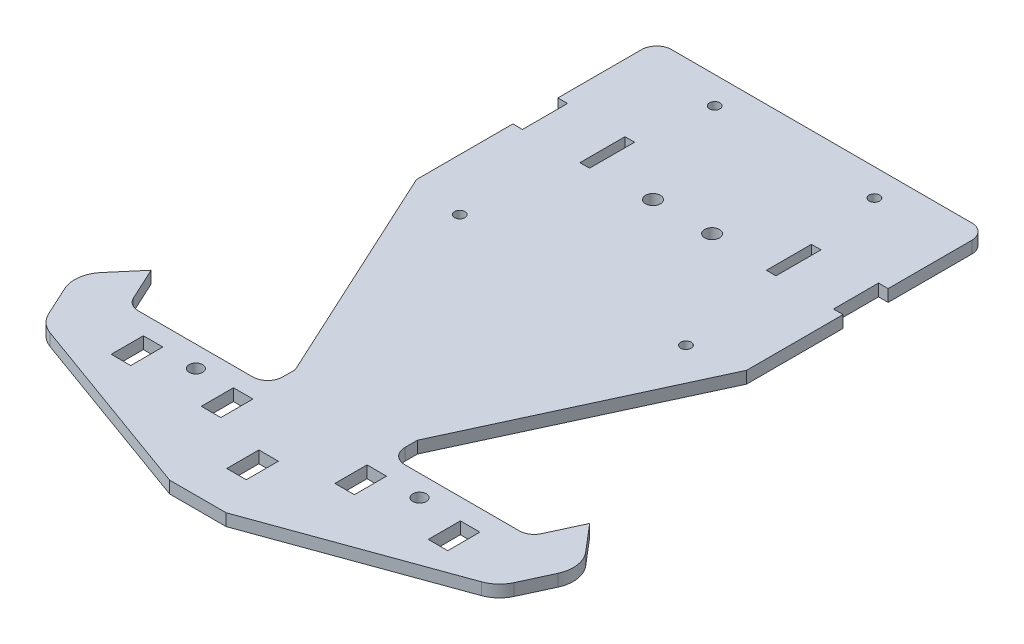
from build123d import *

# Parameters (mm, degrees)
SKETCH1_R           = 2.25
SKETCH1_W           = 6.5
SKETCH1_H           = 10.7
BOSS_EXTRUDE1_DEPTH = 2
SKETCH3_W           = 4
SKETCH3_H           = 15
BOSS_EXTRUDE2_DEPTH = 16
FILLET1_R           = 10
FILLET2_R           = 4
CHAMFER1_SIZE       = 3
CHAMFER1_SIZE2      = 5.196152423
CUT_EXTRUDE2_DEPTH  = 16
SKETCH10_R          = 2.468429883
SKETCH10_R_2        = 1.75
SKETCH10_W          = 3.2
SKETCH10_H          = 15
CUT_EXTRUDE3_DEPTH  = 4
SKETCH12_W          = 53.277727804
SKETCH12_H          = 68.29561081
CUT_EXTRUDE4_DEPTH  = 23


with BuildPart() as part:
    # Sketch1 → Boss-Extrude1 (new body, symmetric)
    with BuildSketch(Plane(origin=(0, -35, 0), x_dir=(1, 0, 0), z_dir=(0, 1, 0))):
        with BuildLine():
            Line((-50, 76.225749335), (50, 76.225749335))
            ThreePointArc((50, 76.225749335), (53.535533906, 74.761283241), (55, 71.225749335))
            Line((55, 71.225749335), (55, -3.774250665))
            Line((55, -3.774250665), (20.347942177, -78.774250665))
            Line((20.347942177, -78.774250665), (20.347942177, -82.95646352))
            ThreePointArc((20.347942177, -82.95646352), (21.812408271, -86.491997426), (25.347942177, -87.95646352))
            Line((25.347942177, -87.95646352), (63.43950887, -87.95646352))
            ThreePointArc((63.43950887, -87.95646352), (66.133427762, -87.168683956), (67.978460954, -85.053583921))
            Line((67.978460954, -85.053583921), (73.038309614, -74.102180936))
            Line((73.038309614, -74.102180936), (80.685361178, -83.086313097))
            ThreePointArc((80.685361178, -83.086313097), (82.977793564, -88.210367772), (82.148282135, -93.762222718))
            Line((82.148282135, -93.762222718), (77.534981649, -103.747128614))
            ThreePointArc((77.534981649, -103.747128614), (75.219554646, -106.919630821), (71.860949779, -108.955741281))
            Line((71.860949779, -108.955741281), (9.40285347, -131.565833476))
            Line((9.40285347, -131.565833476), (-9.40285347, -131.565833476))
            Line((-9.40285347, -131.565833476), (-71.860949779, -108.955741281))
            ThreePointArc((-71.860949779, -108.955741281), (-75.219554646, -106.919630821), (-77.534981649, -103.747128614))
            Line((-77.534981649, -103.747128614), (-82.148282135, -93.762222718))
            ThreePointArc((-82.148282135, -93.762222718), (-82.977793564, -88.210367772), (-80.685361178, -83.086313097))
            Line((-80.685361178, -83.086313097), (-73.038309614, -74.102180936))
            Line((-73.038309614, -74.102180936), (-67.978460954, -85.053583921))
            ThreePointArc((-67.978460954, -85.053583921), (-66.133427762, -87.168683956), (-63.43950887, -87.95646352))
            Line((-63.43950887, -87.95646352), (-25.347942177, -87.95646352))
            ThreePointArc((-25.347942177, -87.95646352), (-21.812408271, -86.491997426), (-20.347942177, -82.95646352))
            Line((-20.347942177, -82.95646352), (-20.347942177, -78.774250665))
            Line((-20.347942177, -78.774250665), (-55, -3.774250665))
            Line((-55, -3.774250665), (-55, 71.225749335))
            ThreePointArc((-55, 71.225749335), (-53.535533906, 74.761283241), (-50, 76.225749335))
        make_face()
        with Locations((-37.233481524, -94.993785432)):
            Circle(SKETCH1_R, mode=Mode.SUBTRACT)
        with Locations((37.266518397, -94.993786505)):
            Circle(SKETCH1_R, mode=Mode.SUBTRACT)
        with Locations((-52.183481524, -99.643785432)):
            Rectangle(SKETCH1_W, SKETCH1_H, mode=Mode.SUBTRACT)
        with Locations((-22.183481524, -99.643785432)):
            Rectangle(SKETCH1_W, SKETCH1_H, mode=Mode.SUBTRACT)
        with Locations((22.316518476, -99.643785432)):
            Rectangle(SKETCH1_W, SKETCH1_H, mode=Mode.SUBTRACT)
        with Locations((54.016518476, -100.243785432)):
            Rectangle(SKETCH1_W, SKETCH1_H, mode=Mode.SUBTRACT)
        with Locations((0, -113.343785432)):
            Rectangle(SKETCH1_W, SKETCH1_H, mode=Mode.SUBTRACT)
    extrude(amount=BOSS_EXTRUDE1_DEPTH, both=True)

    # Sketch3 → Boss-Extrude2 (add)
    with BuildSketch(Plane.XZ.offset(37)):
        with Locations((0, 80.45646352)):
            Rectangle(SKETCH3_W, SKETCH3_H)
    extrude(amount=BOSS_EXTRUDE2_DEPTH)

    # Fillet1
    fillet1_edges = [part.edges().sort_by_distance(p)[0] for p in [
        (0, -53, 87.95646352),
    ]]
    fillet(fillet1_edges, radius=FILLET1_R)

    # Fillet2
    fillet2_edges = [part.edges().sort_by_distance(p)[0] for p in [
        (0, -53, 72.95646352),
    ]]
    fillet(fillet2_edges, radius=FILLET2_R)

    # Chamfer1
    chamfer1_edges = [part.edges().sort_by_distance(p)[0] for p in [
        (0, -37, 87.95646352),
        (-2, -37, 80.45646352),
        (0, -37, 72.95646352),
        (2, -37, 80.45646352),
    ]]
    chamfer1_side = [part.faces().sort_by_distance(p)[0] for p in [
        (-0.006927699, -37, 22.010129075),
    ]]
    chamfer(chamfer1_edges, length=CHAMFER1_SIZE, length2=CHAMFER1_SIZE2, reference=chamfer1_side[0])

    # Sketch7 → Cut-Extrude2 (cut)
    with BuildSketch(Plane.ZY.offset(2)):
        with BuildLine():
            add(Edge.make_bspline(
                [(72.95646352, -42.196152423), (75.352950237, -47.994562928), (72.95646352, -49)],
                knots=[0, 0, 0, 0.704450442, 0.704450442, 0.704450442], degree=2))
            Line((72.95646352, -42.196152423), (72.95646352, -49))
        make_face()
    extrude(amount=-CUT_EXTRUDE2_DEPTH, mode=Mode.SUBTRACT)

    # Sketch10 → Cut-Extrude3 (cut)
    with BuildSketch(Plane.XZ.offset(37)):
        with Locations((-9.838945551, -29.868495219)):
            Circle(SKETCH10_R)
        with Locations((9.838945551, -29.868495219)):
            Circle(SKETCH10_R)
        with Locations((-37.673971089, 6.665090314)):
            Circle(SKETCH10_R_2)
        with Locations((-26.592001418, -67.180357374)):
            Circle(SKETCH10_R_2)
        with Locations((37.673971089, 6.665090314)):
            Circle(SKETCH10_R_2)
        with Locations((26.592001418, -67.180357374)):
            Circle(SKETCH10_R_2)
        with Locations((-53.4, -35.847350079)):
            Rectangle(SKETCH10_W, SKETCH10_H)
        with Locations((-31.047145488, -35.847350079)):
            Rectangle(SKETCH10_W, SKETCH10_H)
        with Locations((31.047145488, -35.847350079)):
            Rectangle(SKETCH10_W, SKETCH10_H)
        with Locations((53.4, -35.847350079)):
            Rectangle(SKETCH10_W, SKETCH10_H)
    extrude(amount=-CUT_EXTRUDE3_DEPTH, mode=Mode.SUBTRACT)

    # Sketch12 → Cut-Extrude4 (cut)
    with BuildSketch(Plane(origin=(0, -37, 0), x_dir=(-1, 0, 0), z_dir=(0, -1, 0))):
        with Locations((0.715137286, -79.433896391)):
            Rectangle(SKETCH12_W, SKETCH12_H)
    extrude(amount=CUT_EXTRUDE4_DEPTH, mode=Mode.SUBTRACT)


solid = part.part
